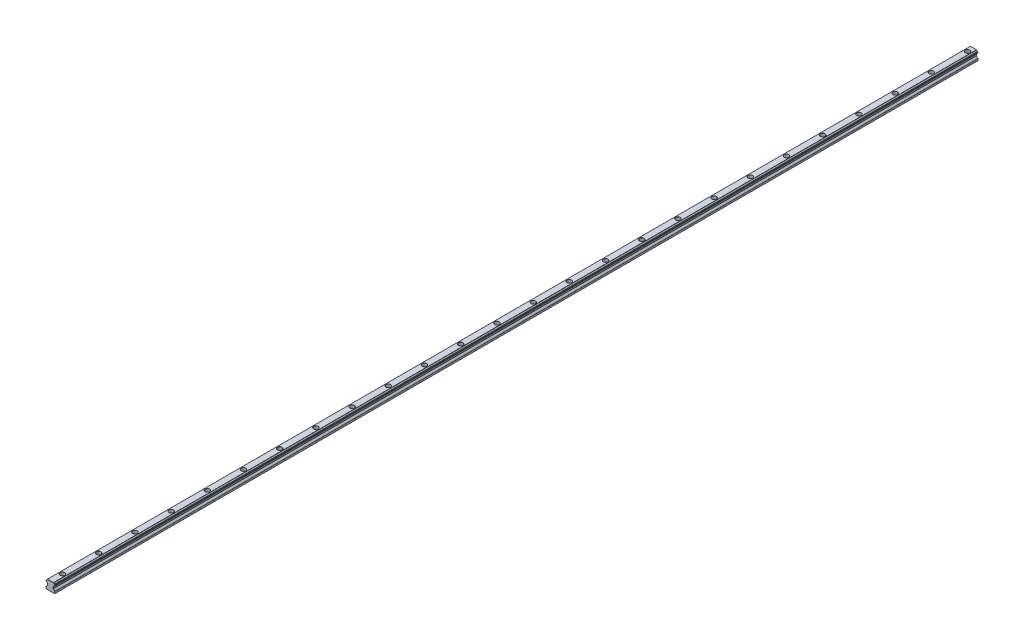
from build123d import *

# Parameters (mm, degrees)
BODY_DEPTH                                 = 1530
AESTHETIC_CHAMFER_SIZE                     = 0.15
PRODUCTION_FILLET_R                        = 0.1
MOUNTING_HOLES_PATTERN_COUNT               = 26
MOUNTING_HOLES_PATTERN_PITCH               = 60
PRODUCTION_FILLET_OF_MOUNTING_HOLES_PATT_R = 0.1


with BuildPart() as part:
    # Rail Profile → Body (new body)
    with BuildSketch(Plane.XY):
        with BuildLine():
            Line((-7, 0), (7, 0))
            Line((7, 0), (7.5, 0.5))
            Line((7.5, 0.5), (7.5, 3.085786438))
            ThreePointArc((7.5, 3.085786438), (7.423879533, 3.46846987), (7.207106781, 3.792893219))
            Line((7.207106781, 3.792893219), (4.867157288, 6.132842712))
            ThreePointArc((4.867157288, 6.132842712), (4.780448187, 6.262612052), (4.75, 6.415685425))
            Line((4.75, 6.415685425), (4.75, 8.584314575))
            ThreePointArc((4.75, 8.584314575), (4.780448187, 8.737387948), (4.867157288, 8.867157288))
            Line((4.867157288, 8.867157288), (5.062965362, 9.062965362))
            ThreePointArc((5.062965362, 9.062965362), (5.134996734, 9.161242682), (5.17409812, 9.27664646))
            ThreePointArc((5.17409812, 9.27664646), (5.61862915, 10.13137085), (6.47335354, 10.57590188))
            ThreePointArc((6.47335354, 10.57590188), (6.694124352, 10.694306692), (6.801170165, 10.920803148))
            ThreePointArc((6.801170165, 10.920803148), (6.915305692, 11.154571658), (7.149074202, 11.268707185))
            ThreePointArc((7.149074202, 11.268707185), (7.399691242, 11.400760606), (7.5, 11.665685425))
            Line((7.5, 11.665685425), (7.5, 12.334314575))
            ThreePointArc((7.5, 12.334314575), (7.399691242, 12.599239394), (7.149074202, 12.731292815))
            ThreePointArc((7.149074202, 12.731292815), (6.915305692, 12.845428342), (6.801170165, 13.079196852))
            ThreePointArc((6.801170165, 13.079196852), (6.694124352, 13.305693308), (6.47335354, 13.42409812))
            ThreePointArc((6.47335354, 13.42409812), (5.61862915, 13.86862915), (5.17409812, 14.72335354))
            ThreePointArc((5.17409812, 14.72335354), (5.134996734, 14.838757318), (5.062965362, 14.937034638))
            Line((5.062965362, 14.937034638), (5, 15))
            Line((5, 15), (-5, 15))
            Line((-5, 15), (-5.062965362, 14.937034638))
            ThreePointArc((-5.062965362, 14.937034638), (-5.134996734, 14.838757318), (-5.17409812, 14.72335354))
            ThreePointArc((-5.17409812, 14.72335354), (-5.61862915, 13.86862915), (-6.47335354, 13.42409812))
            ThreePointArc((-6.47335354, 13.42409812), (-6.694124352, 13.305693308), (-6.801170165, 13.079196852))
            ThreePointArc((-6.801170165, 13.079196852), (-6.915305692, 12.845428342), (-7.149074202, 12.731292815))
            ThreePointArc((-7.149074202, 12.731292815), (-7.399691242, 12.599239394), (-7.5, 12.334314575))
            Line((-7.5, 12.334314575), (-7.5, 11.665685425))
            ThreePointArc((-7.5, 11.665685425), (-7.399691242, 11.400760606), (-7.149074202, 11.268707185))
            ThreePointArc((-7.149074202, 11.268707185), (-6.915305692, 11.154571658), (-6.801170165, 10.920803148))
            ThreePointArc((-6.801170165, 10.920803148), (-6.694124352, 10.694306692), (-6.47335354, 10.57590188))
            ThreePointArc((-6.47335354, 10.57590188), (-5.61862915, 10.13137085), (-5.17409812, 9.27664646))
            ThreePointArc((-5.17409812, 9.27664646), (-5.134996734, 9.161242682), (-5.062965362, 9.062965362))
            Line((-5.062965362, 9.062965362), (-4.867157288, 8.867157288))
            ThreePointArc((-4.867157288, 8.867157288), (-4.780448187, 8.737387948), (-4.75, 8.584314575))
            Line((-4.75, 8.584314575), (-4.75, 6.415685425))
            ThreePointArc((-4.75, 6.415685425), (-4.780448187, 6.262612052), (-4.867157288, 6.132842712))
            Line((-4.867157288, 6.132842712), (-7.207106781, 3.792893219))
            ThreePointArc((-7.207106781, 3.792893219), (-7.423879533, 3.46846987), (-7.5, 3.085786438))
            Line((-7.5, 3.085786438), (-7.5, 0.5))
            Line((-7.5, 0.5), (-7, 0))
        make_face()
    extrude(amount=-BODY_DEPTH)

    # Aesthetic Chamfer
    aesthetic_chamfer_edges = [part.edges().sort_by_distance(p)[0] for p in [
        (7.423879533, 3.46846987, -1530),
        (-5.134996734, 9.161242682, -1530),
        (-4.965061325, 8.965061325, -1530),
        (-4.780448187, 8.737387948, -1530),
        (-4.75, 7.5, -1530),
        (-4.780448187, 6.262612052, -1530),
        (-6.037132034, 4.962867966, -1530),
        (-7.423879533, 3.46846987, -1530),
        (-7.5, 1.792893219, -1530),
        (-7.25, 0.25, -1530),
        (0, 0, -1530),
        (6.037132034, 4.962867966, -1530),
        (4.780448187, 6.262612052, -1530),
        (4.75, 7.5, -1530),
        (4.780448187, 8.737387948, -1530),
        (4.965061325, 8.965061325, -1530),
        (5.134996734, 9.161242682, -1530),
        (5.61862915, 10.13137085, -1530),
        (6.694124352, 10.694306692, -1530),
        (0, 0, 0),
        (-7.25, 0.25, 0),
        (-7.5, 1.792893219, 0),
        (-7.423879533, 3.46846987, 0),
        (-6.037132034, 4.962867966, 0),
        (-4.780448187, 6.262612052, 0),
        (6.915305692, 11.154571658, -1530),
        (-4.75, 7.5, 0),
        (-4.780448187, 8.737387948, 0),
        (-4.965061325, 8.965061325, 0),
        (-5.134996734, 9.161242682, 0),
        (-5.61862915, 10.13137085, 0),
        (-6.694124352, 10.694306692, 0),
        (-6.915305692, 11.154571658, 0),
        (7.25, 0.25, -1530),
        (7.399691242, 11.400760606, -1530),
        (-7.399691242, 11.400760606, 0),
        (-7.5, 12, 0),
        (-7.399691242, 12.599239394, 0),
        (-6.915305692, 12.845428342, 0),
        (-6.694124352, 13.305693308, 0),
        (-5.61862915, 13.86862915, 0),
        (-5.134996734, 14.838757318, 0),
        (-5.031482681, 14.968517319, 0),
        (7.5, 12, -1530),
        (0, 15, 0),
        (5.031482681, 14.968517319, 0),
        (5.134996734, 14.838757318, 0),
        (5.61862915, 13.86862915, 0),
        (6.694124352, 13.305693308, 0),
        (6.915305692, 12.845428342, 0),
        (7.399691242, 12.599239394, 0),
        (7.399691242, 12.599239394, -1530),
        (7.5, 12, 0),
        (7.399691242, 11.400760606, 0),
        (6.915305692, 11.154571658, 0),
        (6.694124352, 10.694306692, 0),
        (5.61862915, 10.13137085, 0),
        (5.134996734, 9.161242682, 0),
        (4.965061325, 8.965061325, 0),
        (4.780448187, 8.737387948, 0),
        (6.915305692, 12.845428342, -1530),
        (4.75, 7.5, 0),
        (4.780448187, 6.262612052, 0),
        (6.037132034, 4.962867966, 0),
        (7.423879533, 3.46846987, 0),
        (7.5, 1.792893219, 0),
        (7.25, 0.25, 0),
        (6.694124352, 13.305693308, -1530),
        (5.61862915, 13.86862915, -1530),
        (5.134996734, 14.838757318, -1530),
        (5.031482681, 14.968517319, -1530),
        (0, 15, -1530),
        (-5.031482681, 14.968517319, -1530),
        (7.5, 1.792893219, -1530),
        (-5.134996734, 14.838757318, -1530),
        (-5.61862915, 13.86862915, -1530),
        (-6.694124352, 13.305693308, -1530),
        (-6.915305692, 12.845428342, -1530),
        (-7.399691242, 12.599239394, -1530),
        (-7.5, 12, -1530),
        (-7.399691242, 11.400760606, -1530),
        (-6.915305692, 11.154571658, -1530),
        (-6.694124352, 10.694306692, -1530),
        (-5.61862915, 10.13137085, -1530),
    ]]
    chamfer(aesthetic_chamfer_edges, length=AESTHETIC_CHAMFER_SIZE)

    # Sketch1 → Mounting Hole (revolve, cut)
    with BuildSketch(Plane(origin=(0, 15, -20), x_dir=(0, 0, 1), z_dir=(1, 0, 0))):
        Polygon((0, 0), (0, 15), (2.35, 15), (2.25, 14.9), (2.25, 5.4), (2.35, 5.3), (3.75, 5.3), (3.75, 0.1), (3.85, 0), align=None)
    mounting_hole = revolve(axis=Axis((0, 21.35, -20), (0, -1, 0)), mode=Mode.SUBTRACT)

    # Production Fillet
    production_fillet_edges = [part.edges().sort_by_distance(p)[0] for p in [
        (0, 9.7, -23.75),
    ]]
    fillet(production_fillet_edges, radius=PRODUCTION_FILLET_R)

    # Mounting Holes Pattern: Mounting Hole ×26
    with Locations(*[(0, 0, -i * MOUNTING_HOLES_PATTERN_PITCH) for i in range(1, MOUNTING_HOLES_PATTERN_COUNT)]):
        add(mounting_hole, mode=Mode.SUBTRACT)

    # Production Fillet of Mounting Holes Patt
    production_fillet_of_mounting_holes_patt_edges = [part.edges().sort_by_distance(p)[0] for p in [
        (0, 9.7, -83.75),
        (0, 9.7, -143.75),
        (0, 9.7, -203.75),
        (0, 9.7, -263.75),
        (0, 9.7, -323.75),
        (0, 9.7, -383.75),
        (0, 9.7, -443.75),
        (0, 9.7, -503.75),
        (0, 9.7, -563.75),
        (0, 9.7, -623.75),
        (0, 9.7, -683.75),
        (0, 9.7, -743.75),
        (0, 9.7, -803.75),
        (0, 9.7, -863.75),
        (0, 9.7, -923.75),
        (0, 9.7, -983.75),
        (0, 9.7, -1043.75),
        (0, 9.7, -1103.75),
        (0, 9.7, -1163.75),
        (0, 9.7, -1223.75),
        (0, 9.7, -1283.75),
        (0, 9.7, -1343.75),
        (0, 9.7, -1403.75),
        (0, 9.7, -1463.75),
        (0, 9.7, -1523.75),
    ]]
    fillet(production_fillet_of_mounting_holes_patt_edges, radius=PRODUCTION_FILLET_OF_MOUNTING_HOLES_PATT_R)


solid = part.part
